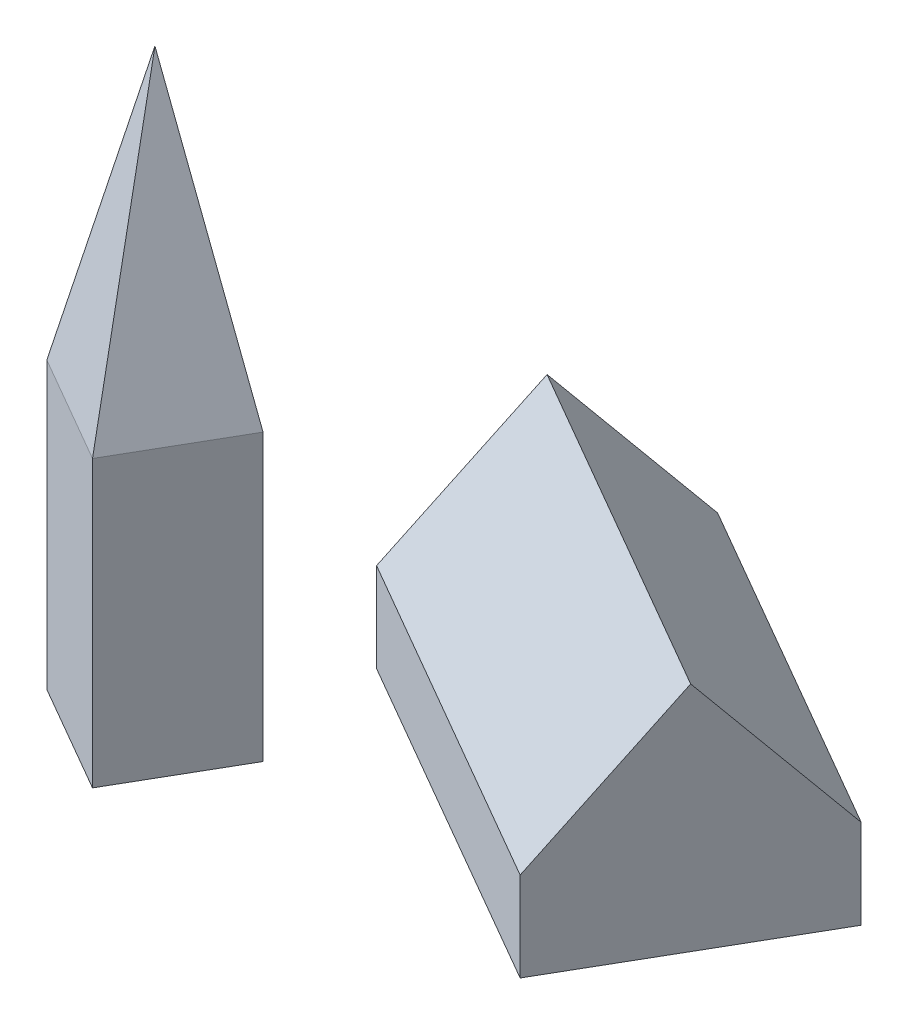
from build123d import *

# Parameters (mm, degrees)
EXTRUDE1_DEPTH = 25
EXTRUDE2_DEPTH = 110
EXTRUDE3_DEPTH = 80


with BuildPart() as part:
    # Sketch1 → Extrude1 (new body)
    with BuildSketch(Plane(origin=(0, 0, 0), x_dir=(1, 0, 0), z_dir=(0, 1, 0))):
        Polygon((0, 0), (95.262794416, -55), (60.262794416, -115.621778265), (-35, -60.621778265), align=None)
    extrude(amount=EXTRUDE1_DEPTH)

    # Sketch2 → Extrude2 (add)
    with BuildSketch(Plane(origin=(95.262794416, 0, 55), x_dir=(0.5, 0, -0.866025404), z_dir=(0.866025404, 0, 0.5))):
        Polygon((-70, 25), (0, 25), (-35, 65), align=None)
    extrude(amount=-EXTRUDE2_DEPTH)


with BuildPart() as body_2:
    # Sketch3 → Extrude3 (new body)
    with BuildSketch(Plane(origin=(0, 0, 0), x_dir=(1, 0, 0), z_dir=(0, 1, 0))):
        Polygon((-58.660254038, -81.602540378), (-28.349364905, -99.102540378), (-45.849364905, -129.413429511), (-76.160254038, -111.913429511), align=None)
    extrude(amount=EXTRUDE3_DEPTH)

    # Sketch4 → Loft1 section 0
    with BuildSketch(Plane(origin=(0, 80, 0), x_dir=(-1, 0, 0), z_dir=(0, 1, 0)), mode=Mode.PRIVATE) as loft1_s0:
        Polygon((58.660254038, 81.602540378), (28.349364905, 99.102540378), (45.849364905, 129.413429511), (76.160254038, 111.913429511), align=None)
    loft([Vertex(-52.254809472, 165, 105.507984945), loft1_s0.sketch])


solid = Compound([part.part, body_2.part])
